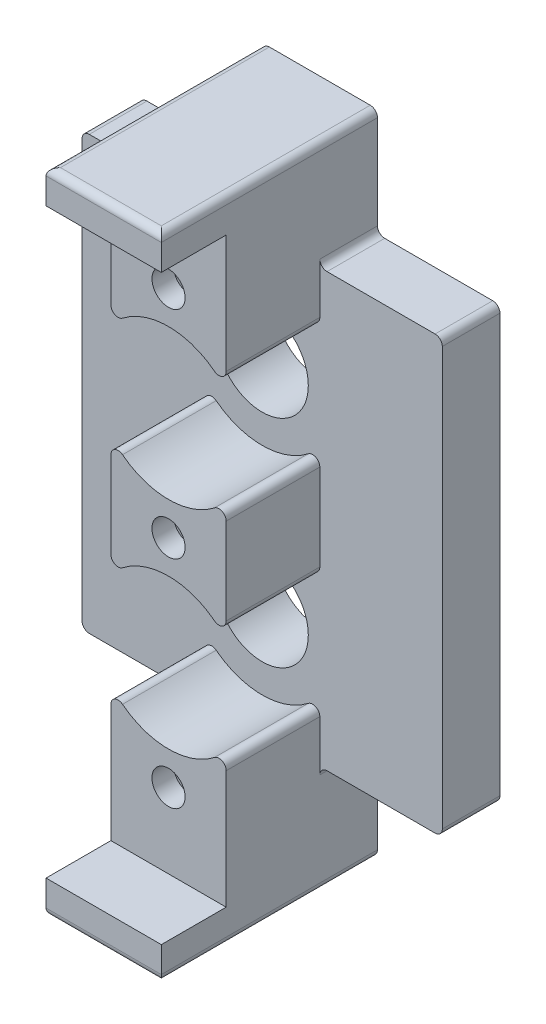
from build123d import *

# Parameters (mm, degrees)
SKETCH_1_W          = 25
SKETCH_1_H          = 30
SKETCH_1_R          = 3.2
EXTRUDE_1_DEPTH     = 4
SKETCH_2_W          = 8
SKETCH_2_H          = 40.4
SKETCH_2_R          = 1.15
EXTRUDE_2_DEPTH     = 6.5
SKETCH_5_R          = 5.2
CUT_EXTRUDE_1_DEPTH = 6.5
SKETCH_6_W          = 8
SKETCH_6_H          = 5.2
EXTRUDE_4_DEPTH     = 4
CUT_EXTRUDE_2_DEPTH = 9
SKETCH_8_W          = 8
SKETCH_8_H          = 2.3
EXTRUDE_5_DEPTH     = 15
FILLET_2_R          = 0.5


with BuildPart() as part:
    # 스케치1 → 보스-돌출1 (new body)
    with BuildSketch(Plane.XY):
        Rectangle(SKETCH_1_W, SKETCH_1_H)
        with Locations((0, 7.5)):
            Circle(SKETCH_1_R, mode=Mode.SUBTRACT)
        with Locations((0, -7.5)):
            Circle(SKETCH_1_R, mode=Mode.SUBTRACT)
    extrude(amount=EXTRUDE_1_DEPTH)

    # 스케치2 → 보스-돌출2 (add)
    with BuildSketch(Plane.XY.offset(4)):
        Rectangle(SKETCH_2_W, SKETCH_2_H)
        Circle(SKETCH_2_R, mode=Mode.SUBTRACT)
        with Locations((0, 15)):
            Circle(SKETCH_2_R, mode=Mode.SUBTRACT)
        with Locations((0, -15)):
            Circle(SKETCH_2_R, mode=Mode.SUBTRACT)
    extrude(amount=EXTRUDE_2_DEPTH)

    # 스케치5 → 컷-돌출1 (cut)
    with BuildSketch(Plane.XY.offset(4)):
        with Locations((0, 7.5)):
            Circle(SKETCH_5_R)
        with Locations((0, -7.5)):
            Circle(SKETCH_5_R)
    extrude(amount=CUT_EXTRUDE_1_DEPTH, mode=Mode.SUBTRACT)

    # 스케치6 → 보스-돌출4 (add)
    with BuildSketch(Plane(origin=(0, 0, 4), x_dir=(-1, 0, 0), z_dir=(0, 0, -1))):
        with Locations((0, 17.6)):
            Rectangle(SKETCH_6_W, SKETCH_6_H)
        with Locations((0, -17.6)):
            Rectangle(SKETCH_6_W, SKETCH_6_H)
    extrude(amount=EXTRUDE_4_DEPTH)

    # 스케치7 → 컷-돌출2 (cut)
    with BuildSketch(Plane(origin=(0, 0, 0), x_dir=(-1, 0, 0), z_dir=(0, 0, -1))):
        Polygon((2.511473671, 15), (1.255736835, 17.175), (-1.255736835, 17.175), (-2.511473671, 15), (-1.255736835, 12.825), (1.255736835, 12.825), align=None)
        Polygon((2.511473671, 0), (1.255736835, 2.175), (-1.255736835, 2.175), (-2.511473671, 0), (-1.255736835, -2.175), (1.255736835, -2.175), align=None)
        Polygon((2.511473671, -15), (1.255736835, -12.825), (-1.255736835, -12.825), (-2.511473671, -15), (-1.255736835, -17.175), (1.255736835, -17.175), align=None)
    extrude(amount=-CUT_EXTRUDE_2_DEPTH, mode=Mode.SUBTRACT)

    # 스케치8 → 보스-돌출5 (add)
    with BuildSketch(Plane(origin=(0, 0, 0), x_dir=(-1, 0, 0), z_dir=(0, 0, -1))):
        with Locations((0, 21.35)):
            Rectangle(SKETCH_8_W, SKETCH_8_H)
        with Locations((0, -21.35)):
            Rectangle(SKETCH_8_W, SKETCH_8_H)
    extrude(amount=-EXTRUDE_5_DEPTH)

    # 필렛2
    fillet_2_edges = [part.edges().sort_by_distance(p)[0] for p in [
        (4, -15, 2),
        (-4, -15, 2),
        (-4, 22.5, 7.5),
        (0, 22.5, 15),
        (4, 22.5, 7.5),
        (0, -22.5, 15),
        (-4, -22.5, 7.5),
        (4, -22.5, 7.5),
        (-4, 4.177350455, 7.25),
        (-4, 10.822649545, 7.25),
        (4, 10.822649545, 7.25),
        (4, 4.177350455, 7.25),
        (-12.5, 15, 2),
        (12.5, 15, 2),
        (-4, -10.822649545, 7.25),
        (-4, -4.177350455, 7.25),
        (12.5, -15, 2),
        (4, -4.177350455, 7.25),
        (4, -10.822649545, 7.25),
        (-12.5, -15, 2),
        (-4, 15, 2),
        (4, 15, 2),
    ]]
    fillet(fillet_2_edges, radius=FILLET_2_R)


solid = part.part
